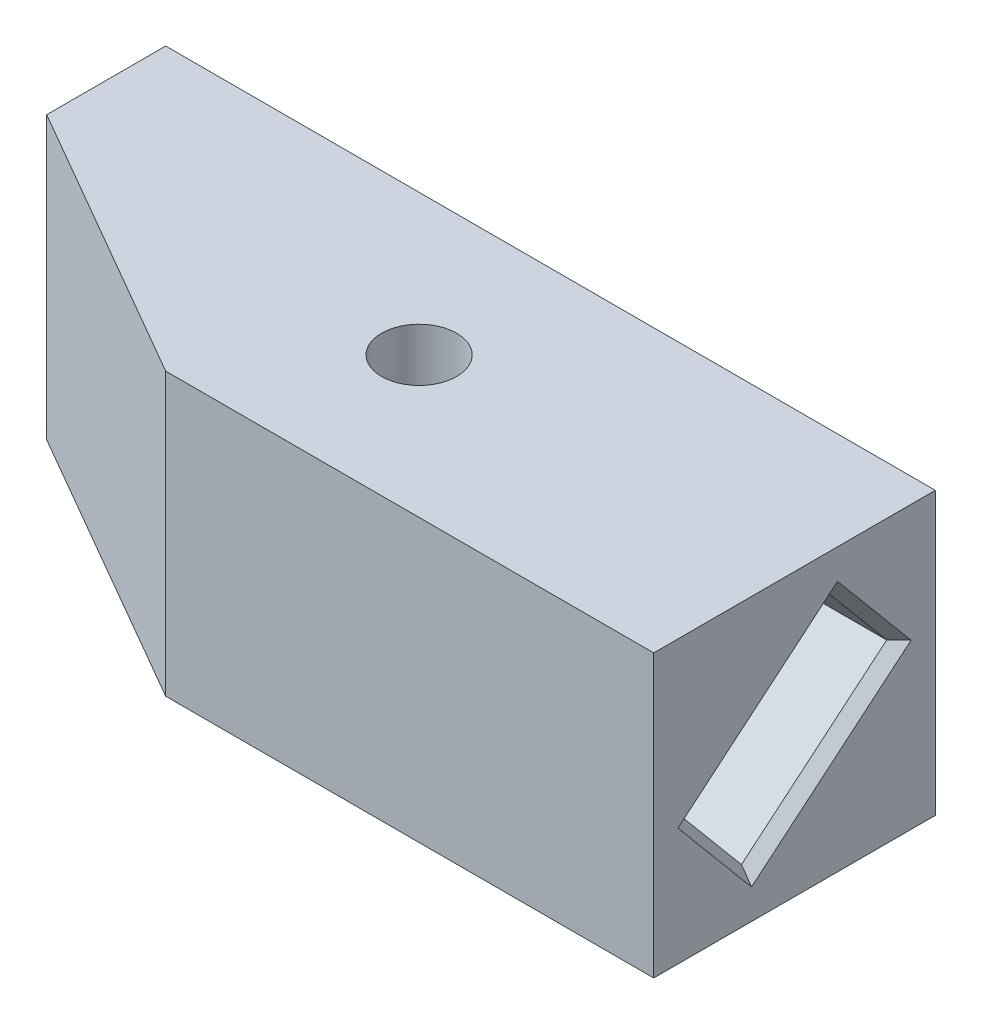
from build123d import *

# Parameters (mm, degrees)
EXTRUDE_1_DEPTH     = 30
SKETCH_2_R          = 4
CUT_EXTRUDE_1_DEPTH = 31
CUT_EXTRUDE_4_DEPTH = 30
SKETCH1_W           = 30
SKETCH1_H           = 30
BOSS_EXTRUDE1_DEPTH = 27
CHAMFER1_SIZE       = 30
CHAMFER1_SIZE2      = 17.320508076
CHAMFER2_SIZE       = 1
CHAMFER2_SIZE2      = 1.191753593


with BuildPart() as part:
    # Эскиз1 → Бобышка-Вытянуть1 (new body)
    with BuildSketch(Plane(origin=(0, 0, 0), x_dir=(1, 0, 0), z_dir=(0, 1, 0))):
        Polygon((-20, 15), (-35, 15), (-35, -15), (-20, -15), (20, -15), (20, 15), align=None)
    extrude(amount=EXTRUDE_1_DEPTH)

    # Эскиз2 → Вырез-Вытянуть1 (cut, through all)
    with BuildSketch(Plane(origin=(0, 30, 0), x_dir=(1, 0, 0), z_dir=(0, 1, 0))):
        with Locations(Location((-20, 0, 0), (0, 0, 270))):  # turned: the seam where the file's is
            Circle(SKETCH_2_R)
    extrude(amount=-CUT_EXTRUDE_1_DEPTH, mode=Mode.SUBTRACT)

    # Эскиз5 → Вырез-Вытянуть4 (cut)
    with BuildSketch(Plane(origin=(20, 0, 0), x_dir=(0, 0, -1), z_dir=(1, 0, 0))):
        Polygon((11.015265685, 17.585328198), (4.458832066, 25.398981518), (-11.015265685, 12.414671802), (-4.458832066, 4.601018482), align=None)
    extrude(amount=-CUT_EXTRUDE_4_DEPTH, mode=Mode.SUBTRACT)

    # Sketch1 → Boss-Extrude1 (add)
    with BuildSketch(Plane.ZY.offset(35)):
        with Locations((0, 15)):
            Rectangle(SKETCH1_W, SKETCH1_H)
    extrude(amount=BOSS_EXTRUDE1_DEPTH)

    # Chamfer1
    chamfer1_edges = [part.edges().sort_by_distance(p)[0] for p in [
        (-62, 15, 15),
    ]]
    chamfer1_side = [part.faces().sort_by_distance(p)[0] for p in [
        (-21, 15, 15),
    ]]
    chamfer(chamfer1_edges, length=CHAMFER1_SIZE, length2=CHAMFER1_SIZE2, reference=chamfer1_side[0])

    # Chamfer2
    chamfer2_edges = [part.edges().sort_by_distance(p)[0] for p in [
        (20, 18.90682666, 3.278216809),
        (20, 8.507845142, 7.737048876),
        (20, 11.09317334, -3.278216809),
        (20, 21.492154858, -7.737048876),
    ]]
    chamfer2_side = [part.faces().sort_by_distance(p)[0] for p in [
        (20, 15, 14.575735931),
    ]]
    chamfer(chamfer2_edges, length=CHAMFER2_SIZE, length2=CHAMFER2_SIZE2, reference=chamfer2_side[0])


solid = part.part
